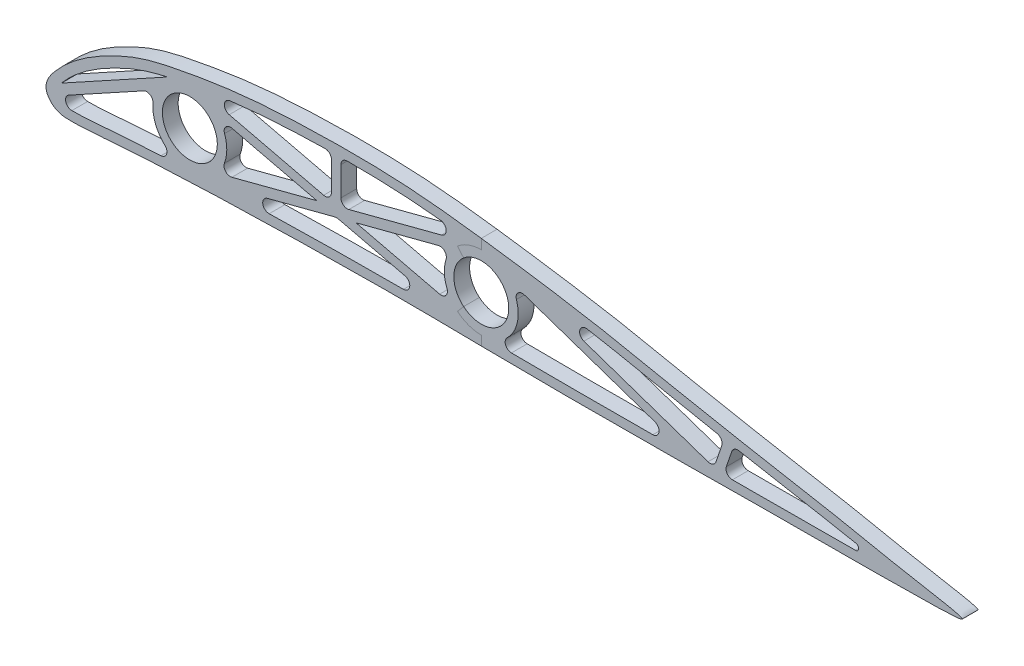
from build123d import *

# Parameters (mm, degrees)
MAINRIBEDGE_DEPTH               = 6.35
TRAILINGEDGE_DEPTH              = 6.35
SKETCH4_R                       = 14.859
SKETCH4_R_2                     = 11.049
SPARHOLES_DEPTH                 = 6.35
REINFORCEMENTS_DEPTH            = 6.35
REARREINFORCEMENTADDITION_REACH = 353.282
SKETCH7_W                       = 3.81
SKETCH7_H                       = 6.35
REARFILLETTRAILINGEDGE_DEPTH    = 6.35
FILLET1_R                       = 2.54
SPLIT1_SURFACE_1_BACK           = 372.272
SPLIT1_SURFACE_1_DEPTH          = 744.544
SPLIT1_SURFACE_2_BACK           = 372.272
SPLIT1_SURFACE_2_DEPTH          = 744.544


with BuildPart() as part:
    # Sketch2 → MainRibEdge (new body)
    with BuildSketch(Plane.XY):
        with BuildLine():
            Line((336.033543448, 6.748002184), (336.033543448, 2.859408992))
            Line((336.033543448, 2.859408992), (332.223543448, 3.651211401))
            add(Edge.make_bspline(
                [(332.223543448, 3.651211401), (331.442162334, 3.813599708), (329.892202923, 4.133427918), (326.683370023, 4.781303863), (322.53723274, 5.595655973), (317.375099369, 6.580129616), (310.311755902, 7.897286963), (301.249708802, 9.546426186), (290.399293502, 11.503192036), (279.814600685, 13.43238274), (269.358296418, 15.38184452), (258.952352154, 17.388751533), (245.021736867, 20.206251177), (227.573510675, 23.830603794), (206.666325018, 27.515993515), (185.595680436, 30.56512285), (164.461232233, 33.491048764), (143.460859563, 35.515027825), (125.855293708, 35.918260783), (111.698667781, 35.751640706), (97.53255455, 35.338046969), (83.460420709, 34.440921821), (69.557958926, 32.737257086), (59.148931361, 31.015761994), (48.696637756, 29.065414767), (40.409151319, 26.952372378), (34.112036004, 24.576177889), (29.406678054, 22.448931348), (24.794296509, 20.123162414), (20.360214995, 17.584123195), (16.782677965, 15.213333136), (14.074634017, 13.193594635), (12.139967848, 11.623924184), (10.337405969, 10.021968357), (8.892622295, 8.604760335), (7.717650368, 7.364282595), (6.504106875, 6.028126656), (5.094018649, 4.328354289), (4.134978848, 2.750764103), (3.766898323, 1.773747642), (3.671843064, 1.242063937), (3.686964581, 0.935440007), (3.756860532, 0.664092903), (4.037763909, 0.130971357), (4.677211547, -0.649559069), (5.633821266, -1.343192609), (6.441340649, -1.660395482), (7.218782802, -1.833174766), (8.195874943, -1.927542143), (9.401107814, -1.959365345), (10.685948482, -1.967755696), (12.380104232, -1.948933772), (14.521297733, -1.87625825), (17.980533341, -1.680309455), (22.373352794, -1.345252452), (27.710739921, -0.90453958), (34.867490659, -0.382107362), (43.808894896, 0.138153988), (54.511635049, 0.613541077), (65.197298897, 1.042319222), (75.895758751, 1.415665565), (86.593740531, 1.724383206), (100.857496847, 2.059864665), (118.680474228, 2.35933128), (140.087623693, 2.533191475), (161.515300562, 2.365223454), (182.867109219, 2.036676094), (204.169473539, 1.894315434), (225.534200822, 1.889460584), (243.379803432, 1.962208718), (257.561952683, 2.072147568), (268.129487106, 2.18110916), (278.733989184, 2.292747533), (289.459215441, 2.384735014), (300.452604741, 2.426198189), (309.690727783, 2.428016051), (316.920862467, 2.434561147), (322.222497088, 2.446734854), (326.494524951, 2.467407298), (329.814256558, 2.49297224), (331.415580066, 2.509011748), (332.223543448, 2.51813868)],
                knots=[0.047492313, 0.047492313, 0.047492313, 0.047492313, 0.051026993, 0.054561673, 0.061631032, 0.068700392, 0.075769752, 0.089908471, 0.10404719, 0.118185909, 0.132324629, 0.146463348, 0.160602067, 0.188879506, 0.217156944, 0.245434383, 0.273711821, 0.30198926, 0.330266699, 0.344405418, 0.358544137, 0.386821576, 0.400960295, 0.415099014, 0.429237733, 0.443376453, 0.450445812, 0.457515172, 0.464584532, 0.471653891, 0.478723251, 0.482257931, 0.485792611, 0.48932729, 0.49286197, 0.49462931, 0.49639665, 0.49993133, 0.50346601, 0.50523335, 0.50700069, 0.508768029, 0.510535369, 0.512302709, 0.514070049, 0.517604729, 0.519372069, 0.521139409, 0.522906749, 0.524674089, 0.526441429, 0.528208768, 0.531743448, 0.535278128, 0.542347488, 0.549416847, 0.556486207, 0.570624926, 0.584763646, 0.598902365, 0.613041084, 0.627179803, 0.641318523, 0.669595961, 0.6978734, 0.726150838, 0.754428277, 0.782705715, 0.810983154, 0.839260592, 0.853399312, 0.867538031, 0.88167675, 0.89581547, 0.909954189, 0.924092908, 0.931162268, 0.938231627, 0.945300987, 0.948835667, 0.952370347, 0.952370347, 0.952370347, 0.952370347], degree=3))
            Line((332.223543448, 2.51813868), (336.033543448, 2.561177276))
            Line((336.033543448, 2.561177276), (336.033543448, -1.242994162))
            add(Edge.make_bspline(
                [(336.033543448, 6.748002184), (334.468246688, 7.074980478), (322.12721063, 9.665264587), (293.889881317, 14.72271665), (257.594458742, 21.359380606), (220.709965271, 29.306661511), (183.775962572, 34.730897448), (146.926816767, 39.634152375), (109.928619569, 39.855493313), (79.122071309, 38.221707773), (54.668166922, 34.165196241), (39.098671681, 30.915673791), (27.05666798, 25.655524099), (17.786881507, 20.691298196), (10.020297457, 15.089976149), (3.62310726, 8.803462506), (-2.539027938, 0.957307572), (3.844642943, -5.538740568), (10.821283108, -5.895468534), (18.497431461, -5.504672725), (27.686188136, -4.711761272), (39.945064963, -3.852138324), (55.285518105, -3.152699353), (79.824801052, -2.211431766), (110.510539231, -1.5147752), (147.340763774, -1.180733861), (184.182113819, -1.850240341), (220.967951397, -1.958896964), (257.975803971, -1.783034555), (294.130761276, -1.29513191), (322.154040261, -1.425305505), (334.511641951, -1.264632494), (336.033543448, -1.242994162)],
                knots=[0.042905298, 0.042905298, 0.042905298, 0.042905298, 0.049952062, 0.09968381, 0.149415558, 0.199258544, 0.248703056, 0.297849082, 0.346623035, 0.395438522, 0.420070942, 0.445103862, 0.458263472, 0.47204953, 0.487005632, 0.49545517, 0.509298809, 0.518413364, 0.524589237, 0.536779458, 0.548989568, 0.561192853, 0.585584555, 0.60996345, 0.658714952, 0.707463407, 0.756228363, 0.804980995, 0.853733783, 0.902478123, 0.951230531, 0.957929822, 0.957929822, 0.957929822, 0.957929822], degree=3))
        make_face()
    extrude(amount=MAINRIBEDGE_DEPTH)

    # Sketch3 → TrailingEdge (add)
    with BuildSketch(Plane.XY.offset(6.35)):
        with BuildLine():
            Line((336.033543448, 6.748002184), (336.033543448, -1.242994162))
            add(Edge.make_bspline(
                [(336.033543448, -1.242994162), (340.048666493, -1.185907312), (350.085385672, -1.013128299), (378.905608876, -0.784903512), (350.055453627, 3.842589288), (340.005005957, 5.918394617), (336.033543448, 6.748002184)],
                knots=[0.957929822, 0.957929822, 0.957929822, 0.957929822, 0.975604078, 1, 1.025026287, 1.042905298, 1.042905298, 1.042905298, 1.042905298], degree=3))
        make_face()
    extrude(amount=-TRAILINGEDGE_DEPTH)

    # Sketch4 → SparHoles (add)
    with BuildSketch(Plane.XY.offset(6.35)):
        with Locations((57.717037087, 15.610548884)):
            Circle(SKETCH4_R)
        with Locations((57.717037087, 15.610548884)):
            Circle(SKETCH4_R_2, mode=Mode.SUBTRACT)
        with Locations((174.906051742, 17.025541946)):
            Circle(SKETCH4_R)
        with Locations((174.906051742, 17.025541946)):
            Circle(SKETCH4_R_2, mode=Mode.SUBTRACT)
    extrude(amount=-SPARHOLES_DEPTH)

    # Sketch5 → Reinforcements (add)
    with BuildSketch(Plane.XY.offset(6.35)):
        Polygon((56.766541042, 32.249190807), (114.651766139, 18.446959901), (114.651766139, 35.773917134), (114.651766139, 37.043917134), (118.461766139, 37.043917134), (118.461766139, 35.819240888), (118.461766139, 18.446959901), (176.425554251, 33.592301529), (188.52461038, 30.128238771), (270.29707029, 2.195040786), (270.29707029, -0.344959214), (258.824238777, -0.452037739), (258.824238777, 2.087962261), (177.388731693, 29.90605829), (124.523927018, 16.093028587), (175.153412533, 4.020865984), (174.26972448, 0.314763526), (116.686090733, 14.045082585), (58.80253373, -1.079295479), (57.839356288, 2.60694776), (108.806028992, 15.924015102), (55.882852988, 28.54308835), (3.14352936, -0.44592394), (1.308275204, 2.892929483), (54.047598832, 31.881941773), align=None)
    extrude(amount=-REINFORCEMENTS_DEPTH)

    # Sketch7 → RearReinforcementAddition (add, up to next)
    with BuildSketch(Plane(origin=(28.916141141, 84.649956426, 0), x_dir=(0.9463112938720156, -0.3232567634099429, 0), z_dir=(0.3232567634099429, 0.9463112938720157, 0)), mode=Mode.PRIVATE) as rearreinforcementaddition_sk1:
        with Locations((255.048440564, -3.175)):
            Rectangle(SKETCH7_W, SKETCH7_H)
    rearreinforcementaddition_tool1 = extrude(rearreinforcementaddition_sk1.sketch, amount=REARREINFORCEMENTADDITION_REACH, mode=Mode.PRIVATE) - part.part
    add(rearreinforcementaddition_tool1.solids().sort_by_distance((270.271361, 2.203823, 3.175))[0])

    # Sketch9 → RearFilletTrailingEdge (add)
    with BuildSketch(Plane.XY.offset(6.35)):
        with BuildLine():
            Line((336.033543448, 2.859408992), (332.223543448, 3.651211401))
            add(Edge.make_bspline(
                [(332.223543448, 3.651211401), (331.442162334, 3.813599708), (329.892202923, 4.133427918), (327.696271183, 4.576795147), (326.275362578, 4.859100359), (325.667658223, 4.979078247)],
                knots=[0.876972344, 0.876972344, 0.876972344, 0.876972344, 0.880507023, 0.884041703, 0.886648031, 0.886648031, 0.886648031, 0.886648031], degree=3))
            ThreePointArc((325.667658223, 4.979078247), (326.685974287, 3.612954932), (325.428515843, 2.463146784))
            add(Edge.make_bspline(
                [(325.428515843, 2.463146784), (326.062192496, 2.466561244), (327.535685019, 2.475425174), (329.814256558, 2.49297224), (331.415580066, 2.509011748), (332.223543448, 2.51813868)],
                knots=[0.117074417, 0.117074417, 0.117074417, 0.117074417, 0.119709482, 0.123244161, 0.126778841, 0.126778841, 0.126778841, 0.126778841], degree=3))
            Line((332.223543448, 2.51813868), (336.033543448, 2.561177276))
            Line((336.033543448, 2.561177276), (336.033543448, 2.859408992))
        make_face()
    extrude(amount=-REARFILLETTRAILINGEDGE_DEPTH)

    # Fillet1
    fillet1_edges = [part.edges().sort_by_distance(p)[0] for p in [
        (188.531300292, 30.125953519, 3.175),
        (185.930269697, 26.988297562, 3.175),
        (174.777720126, 2.167096132, 3.175),
        (171.926336276, 32.41670215, 3.175),
        (258.823409672, 2.08824548, 3.175),
        (164.31279197, 6.605718127, 3.175),
        (163.22088539, 26.204145779, 3.175),
        (166.014976233, 2.283036798, 3.175),
        (4.100146859, 0.07989616, 3.175),
        (68.506673902, 5.39420813, 3.175),
        (67.165556558, 1.105876365, 3.175),
        (60.850881373, 31.275315207, 3.175),
        (68.850507055, 25.451063477, 3.175),
        (44.42010741, 22.242407006, 3.175),
        (116.686090733, 14.045082585, 3.175),
        (118.461766139, 18.446959901, 3.175),
        (114.651766139, 18.446959901, 3.175),
        (114.651766139, 35.773917134, 3.175),
        (118.461766139, 35.819240888, 3.175),
        (58.264783774, 0.761648097, 3.175),
        (272.557450768, 14.789337356, 3.175),
        (276.342118459, 14.082387814, 3.175),
        (272.291606523, 2.224800827, 3.175),
        (268.468637917, 2.819627151, 3.175),
    ]]
    fillet(fillet1_edges, radius=FILLET1_R)


with BuildPart() as body_2:
    # Split1: the piece behind the surface
    add(part.part)
    # Split1 surface: a surface, the sketch's curves swept straight by 744.544 mm
    with BuildLine(Plane.XY.offset(6.35).offset(-SPLIT1_SURFACE_1_BACK), mode=Mode.PRIVATE) as split1_surface_1_path:
        Line((174.906051742, 35.863280391), (174.906051742, 31.884541946))
        ThreePointArc((174.906051742, 31.884541946), (169.823974432, 30.988434598), (165.35487065, 28.408196326))
        Line((165.35487065, 28.408196326), (167.803891443, 25.489566998))
        ThreePointArc((167.803891443, 25.489566998), (185.955051742, 17.025541946), (167.803891443, 8.561516894))
        Line((167.803891443, 8.561516894), (165.35487065, 5.642887565))
        ThreePointArc((165.35487065, 5.642887565), (169.823974432, 3.062649293), (174.906051742, 2.166541946))
        Line((174.906051742, 2.166541946), (174.906051742, -1.645230909))
    split1_surface_1 = Shell.extrude(split1_surface_1_path.wire(), (0 * SPLIT1_SURFACE_1_DEPTH, 0 * SPLIT1_SURFACE_1_DEPTH, 1 * SPLIT1_SURFACE_1_DEPTH))
    split(bisect_by=split1_surface_1, keep=Keep.BOTTOM)


with BuildPart() as part_1:
    add(part.part)

    # Split1: split by a surface, the side it looks to stays
    # Split1 surface: a surface, the sketch's curves swept straight by 744.544 mm
    with BuildLine(Plane.XY.offset(6.35).offset(-SPLIT1_SURFACE_2_BACK), mode=Mode.PRIVATE) as split1_surface_2_path:
        Line((174.906051742, 35.863280391), (174.906051742, 31.884541946))
        ThreePointArc((174.906051742, 31.884541946), (169.823974432, 30.988434598), (165.35487065, 28.408196326))
        Line((165.35487065, 28.408196326), (167.803891443, 25.489566998))
        ThreePointArc((167.803891443, 25.489566998), (185.955051742, 17.025541946), (167.803891443, 8.561516894))
        Line((167.803891443, 8.561516894), (165.35487065, 5.642887565))
        ThreePointArc((165.35487065, 5.642887565), (169.823974432, 3.062649293), (174.906051742, 2.166541946))
        Line((174.906051742, 2.166541946), (174.906051742, -1.645230909))
    split1_surface_2 = Shell.extrude(split1_surface_2_path.wire(), (0 * SPLIT1_SURFACE_2_DEPTH, 0 * SPLIT1_SURFACE_2_DEPTH, 1 * SPLIT1_SURFACE_2_DEPTH))
    split(bisect_by=split1_surface_2, keep=Keep.TOP)


solid = Compound([body_2.part, part_1.part])
